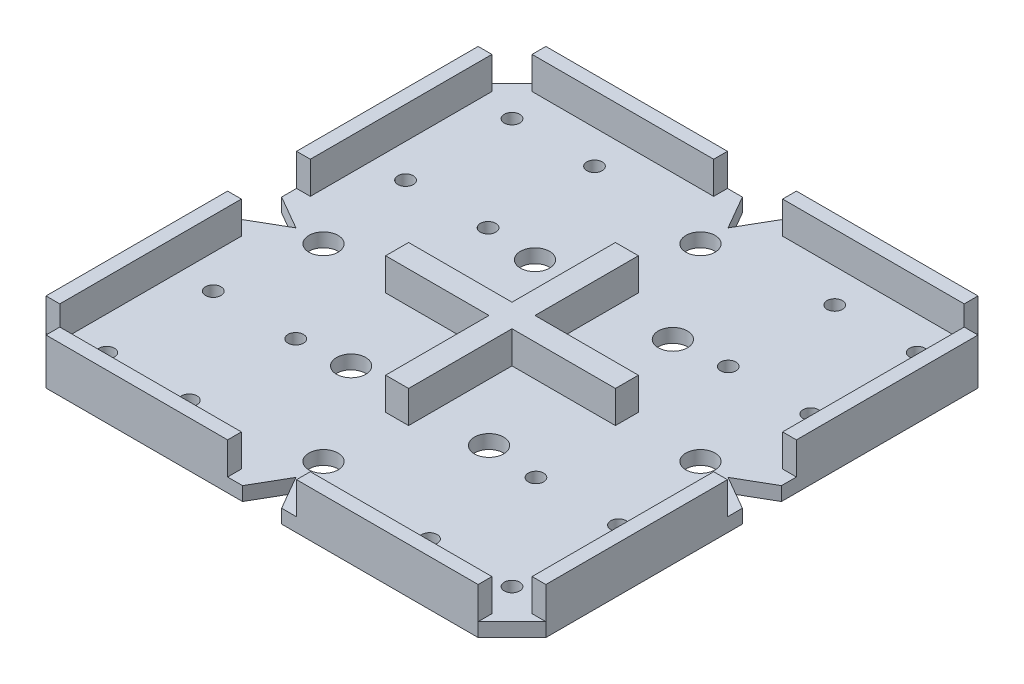
from build123d import *

# Parameters (mm, degrees)
SKETCH1_W           = 120
SKETCH1_H           = 120
BOSS_EXTRUDE1_DEPTH = 3
SKETCH3_R           = 1.675
CUT_EXTRUDE2_DEPTH  = 4
CUT_EXTRUDE3_DEPTH  = 4
SKETCH5_R           = 3.175
CUT_EXTRUDE4_DEPTH  = 3
SKETCH8_W           = 5
SKETCH8_H           = 50
SKETCH8_W_2         = 50
SKETCH8_H_2         = 5
SKETCH8_W_3         = 39.509618943
SKETCH8_H_3         = 3
SKETCH8_W_4         = 3
SKETCH8_H_4         = 39.509618943
BOSS_EXTRUDE5_DEPTH = 7
SKETCH9_W           = 120
SKETCH9_H           = 120
CUT_EXTRUDE5_DEPTH  = 4


with BuildPart() as part:
    # Sketch1 → Boss-Extrude1 (new body)
    with BuildSketch(Plane(origin=(0, 0, 0), x_dir=(1, 0, 0), z_dir=(0, 1, 0))):
        with Locations((60, 60)):
            Rectangle(SKETCH1_W, SKETCH1_H)
    extrude(amount=BOSS_EXTRUDE1_DEPTH)

    # Sketch3 → Cut-Extrude2 (cut, through all)
    with BuildSketch(Plane(origin=(0, 3, 0), x_dir=(1, 0, 0), z_dir=(0, 1, 0))):
        with Locations((15.92, 15.92)):
            Circle(SKETCH3_R)
        with Locations((33.87, 15.92)):
            Circle(SKETCH3_R)
        with Locations((15.92, 39.08)):
            Circle(SKETCH3_R)
        with Locations((33.87, 39.08)):
            Circle(SKETCH3_R)
        with Locations((33.87, 80.92)):
            Circle(SKETCH3_R)
        with Locations((15.92, 80.92)):
            Circle(SKETCH3_R)
        with Locations((33.87, 104.08)):
            Circle(SKETCH3_R)
        with Locations((15.92, 104.08)):
            Circle(SKETCH3_R)
        with Locations((86.13, 39.08)):
            Circle(SKETCH3_R)
        with Locations((104.08, 39.08)):
            Circle(SKETCH3_R)
        with Locations((86.13, 15.92)):
            Circle(SKETCH3_R)
        with Locations((104.08, 15.92)):
            Circle(SKETCH3_R)
        with Locations((104.08, 104.08)):
            Circle(SKETCH3_R)
        with Locations((86.13, 104.08)):
            Circle(SKETCH3_R)
        with Locations((104.08, 80.92)):
            Circle(SKETCH3_R)
        with Locations((86.13, 80.92)):
            Circle(SKETCH3_R)
    extrude(amount=-CUT_EXTRUDE2_DEPTH, mode=Mode.SUBTRACT)

    # Sketch4 → Cut-Extrude3 (cut, through all)
    with BuildSketch(Plane(origin=(0, 3, 0), x_dir=(1, 0, 0), z_dir=(0, 1, 0))):
        Polygon((52.5, 120), (60, 107.009618943), (67.5, 120), align=None)
        Polygon((0, 67.5), (12.990381057, 60), (0, 52.5), align=None)
        Polygon((120, 67.5), (107.009618943, 60), (120, 52.5), align=None)
        Polygon((67.5, 0), (60, 12.990381057), (52.5, 0), align=None)
    extrude(amount=-CUT_EXTRUDE3_DEPTH, mode=Mode.SUBTRACT)

    # Sketch5 → Cut-Extrude4 (cut)
    with BuildSketch(Plane(origin=(0, 3, 0), x_dir=(1, 0, 0), z_dir=(0, 1, 0))):
        with Locations((75, 40)):
            Circle(SKETCH5_R)
        with Locations((45, 40)):
            Circle(SKETCH5_R)
        with Locations((45, 80)):
            Circle(SKETCH5_R)
        with Locations((75, 80)):
            Circle(SKETCH5_R)
        with Locations((101.009618943, 60)):
            Circle(SKETCH5_R)
        with Locations((60, 18.990381057)):
            Circle(SKETCH5_R)
        with Locations((60, 101.009618943)):
            Circle(SKETCH5_R)
        with Locations((18.990381057, 60)):
            Circle(SKETCH5_R)
    extrude(amount=-CUT_EXTRUDE4_DEPTH, mode=Mode.SUBTRACT)

    # Sketch8 → Boss-Extrude5 (add)
    with BuildSketch(Plane(origin=(0, 3, 0), x_dir=(1, 0, 0), z_dir=(0, 1, 0))):
        with Locations((60, 60)):
            Rectangle(SKETCH8_W, SKETCH8_H)
        with Locations((60, 60)):
            Rectangle(SKETCH8_W_2, SKETCH8_H_2)
        with Locations((87.254809472, 112.8775)):
            Rectangle(SKETCH8_W_3, SKETCH8_H_3)
        with Locations((112.8775, 87.254809472)):
            Rectangle(SKETCH8_W_4, SKETCH8_H_4)
        with Locations((112.8775, 32.745190529)):
            Rectangle(SKETCH8_W_4, SKETCH8_H_4)
        with Locations((87.254809472, 7.1225)):
            Rectangle(SKETCH8_W_3, SKETCH8_H_3)
        with Locations((32.745190529, 7.1225)):
            Rectangle(SKETCH8_W_3, SKETCH8_H_3)
        with Locations((7.1225, 32.745190529)):
            Rectangle(SKETCH8_W_4, SKETCH8_H_4)
        with Locations((7.1225, 87.254809472)):
            Rectangle(SKETCH8_W_4, SKETCH8_H_4)
        with Locations((32.745190529, 112.8775)):
            Rectangle(SKETCH8_W_3, SKETCH8_H_3)
    extrude(amount=BOSS_EXTRUDE5_DEPTH)

    # Sketch9 → Cut-Extrude5 (cut, through all)
    with BuildSketch(Plane(origin=(0, 3, 0), x_dir=(1, 0, 0), z_dir=(0, 1, 0))):
        with Locations((60, 60)):
            Rectangle(SKETCH9_W, SKETCH9_H)
        Polygon((107.009618943, 114.3775), (12.990381057, 114.3775), (5.6225, 107.009618943), (5.6225, 12.990381057), (12.990381057, 5.6225), (107.009618943, 5.6225), (114.3775, 12.990381057), (114.3775, 107.009618943), align=None, mode=Mode.SUBTRACT)
    extrude(amount=-CUT_EXTRUDE5_DEPTH, mode=Mode.SUBTRACT)


solid = part.part
